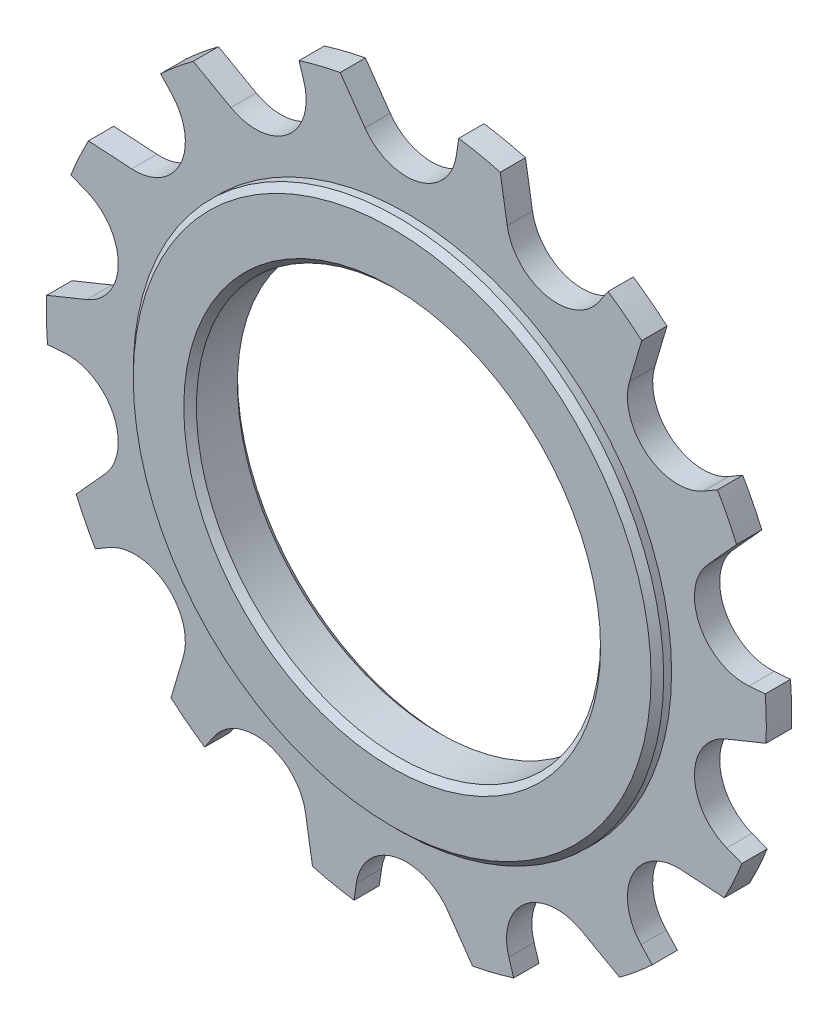
from build123d import *

# Parameters (mm, degrees)
ESQUISSE1_R                  = 28.5
EXTRUSION1_DEPTH             = 1
ENL_V_MAT_EXTRU_1_DEPTH      = 2
R_P_TITION_CIRCULAIRE1_COUNT = 14
ESQUISSE3_R                  = 21
EXTRUSION2_DEPTH             = 2.125
ESQUISSE4_R                  = 16
ENL_V_MAT_EXTRU_2_DEPTH      = 3.125
ENL_V_MAT_EXTRU_2_DEPTH_BACK = 3.125
CHANFREIN1_SIZE              = 0.5


with BuildPart() as part:
    # Esquisse1 → Extrusion1 (new body, symmetric)
    with BuildSketch(Plane.XY):
        Circle(ESQUISSE1_R)
    extrude(amount=EXTRUSION1_DEPTH, both=True)

    # Esquisse2 → Enlèv. mat.-Extru.1 (cut, symmetric)
    with BuildSketch(Plane.XY):
        with BuildLine():
            Line((-5.2427476, 28.013632353), (-3.276608177, 25.205694255))
            ThreePointArc((-3.276608177, 25.205694255), (0.921435362, 23.607576992), (3.957459741, 26.918181818))
            Line((3.957459741, 26.918181818), (4.145454545, 28.196900656))
            ThreePointArc((4.145454545, 28.196900656), (-0.556246195, 28.49457124), (-5.2427476, 28.013632353))
        make_face()
    enl_v_mat_extru_1 = extrude(amount=ENL_V_MAT_EXTRU_1_DEPTH, both=True, mode=Mode.SUBTRACT)

    # Répétition circulaire1: Enlèv. mat.-Extru.1 ×14 about axis
    r_p_tition_circulaire1_axis = Axis((0, 0, 0), (0, 0, 1))
    for i in range(1, R_P_TITION_CIRCULAIRE1_COUNT):
        add(enl_v_mat_extru_1.rotate(r_p_tition_circulaire1_axis, i * 360 / R_P_TITION_CIRCULAIRE1_COUNT), mode=Mode.SUBTRACT)

    # Esquisse3 → Extrusion2 (add, symmetric)
    with BuildSketch(Plane.XY):
        Circle(ESQUISSE3_R)
    extrude(amount=EXTRUSION2_DEPTH, both=True)

    # Esquisse4 → Enlèv. mat.-Extru.2 (cut, two sides)
    with BuildSketch(Plane.XY) as enl_v_mat_extru_2_sk:
        Circle(ESQUISSE4_R)
    extrude(amount=ENL_V_MAT_EXTRU_2_DEPTH, mode=Mode.SUBTRACT)
    extrude(enl_v_mat_extru_2_sk.sketch, amount=-ENL_V_MAT_EXTRU_2_DEPTH_BACK, mode=Mode.SUBTRACT)

    # Chanfrein1
    chanfrein1_edges = [part.edges().sort_by_distance(p)[0] for p in [
        (-21, 0, -2.125),
        (-21, 0, 2.125),
        (-16, 0, -2.125),
        (-16, 0, 2.125),
    ]]
    chamfer(chanfrein1_edges, length=CHANFREIN1_SIZE)


solid = part.part
